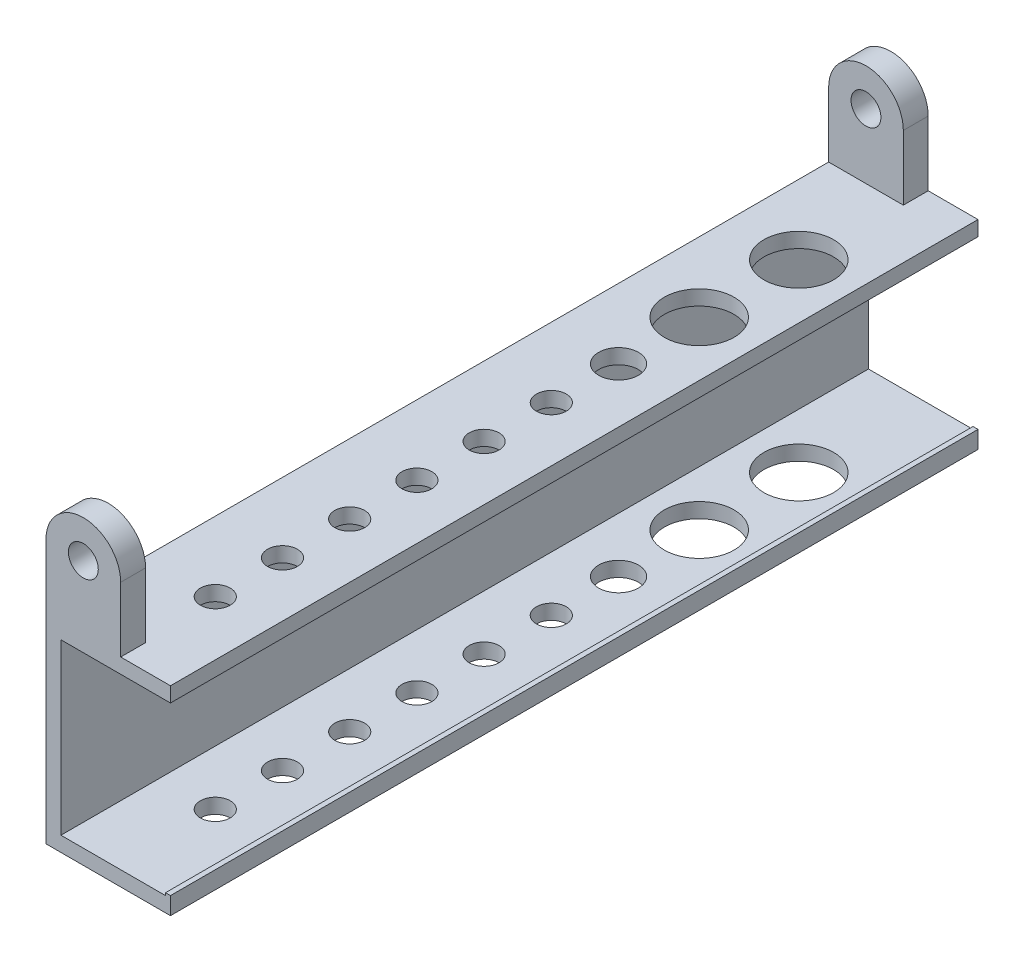
from build123d import *

# Parameters (mm, degrees)
EXTRUDE_1_DEPTH     = 162.2
SKETCH_4_R          = 3
EXTRUDE_2_DEPTH     = 5
SKETCH_5_R          = 3
EXTRUDE_3_DEPTH     = 5
SKETCH_6_W          = 1
SKETCH_6_H          = 0.5
EXTRUDE_4_DEPTH     = 162.2
SKETCH_3_R          = 3
SKETCH_3_R_2        = 7
SKETCH_3_R_3        = 4
CUT_EXTRUDE_1_DEPTH = 40


with BuildPart() as part:
    # 스케치1 → 보스-돌출1 (new body)
    with BuildSketch(Plane.XY):
        Polygon((0, -20), (25, -20), (25, -17), (3, -17), (3, 17), (25, 17), (25, 20), (0, 20), align=None)
    extrude(amount=EXTRUDE_1_DEPTH)

    # 스케치4 → 보스-돌출2 (add)
    with BuildSketch(Plane.XY.offset(162.2)):
        with BuildLine():
            Line((0, 33), (0, 20))
            Line((0, 20), (15, 20))
            Line((15, 20), (15, 33))
            ThreePointArc((15, 33), (7.5, 40.5), (0, 33))
        make_face()
        with Locations((7.5, 33)):
            Circle(SKETCH_4_R, mode=Mode.SUBTRACT)
    extrude(amount=-EXTRUDE_2_DEPTH)

    # 스케치5 → 보스-돌출3 (add)
    with BuildSketch(Plane(origin=(0, 0, 0), x_dir=(-1, 0, 0), z_dir=(0, 0, -1))):
        with BuildLine():
            ThreePointArc((0, 33), (-7.5, 40.5), (-15, 33))
            Line((-15, 33), (-15, 20))
            Line((-15, 20), (0, 20))
            Line((0, 20), (0, 33))
        make_face()
        with Locations((-7.5, 33)):
            Circle(SKETCH_5_R, mode=Mode.SUBTRACT)
    extrude(amount=-EXTRUDE_3_DEPTH)

    # 스케치6 → 보스-돌출4 (add)
    with BuildSketch(Plane.XY.offset(162.2)):
        with Locations((24.5, -16.75)):
            Rectangle(SKETCH_6_W, SKETCH_6_H)
    extrude(amount=-EXTRUDE_4_DEPTH)

    # 스케치3 → 컷-돌출1 (cut)
    with BuildSketch(Plane(origin=(0, 20, 0), x_dir=(1, 0, 0), z_dir=(0, 1, 0))):
        with Locations((14, -142.2)):
            Circle(SKETCH_3_R)
        with Locations((14, -128.7)):
            Circle(SKETCH_3_R)
        with Locations((14, -115.2)):
            Circle(SKETCH_3_R)
        with Locations((14, -101.7)):
            Circle(SKETCH_3_R)
        with Locations((14, -74.7)):
            Circle(SKETCH_3_R)
        with Locations((14, -88.2)):
            Circle(SKETCH_3_R)
        with Locations((14, -45)):
            Circle(SKETCH_3_R_2)
        with Locations((14, -25)):
            Circle(SKETCH_3_R_2)
        with Locations((14, -61.2)):
            Circle(SKETCH_3_R_3)
    extrude(amount=-CUT_EXTRUDE_1_DEPTH, mode=Mode.SUBTRACT)


solid = part.part
